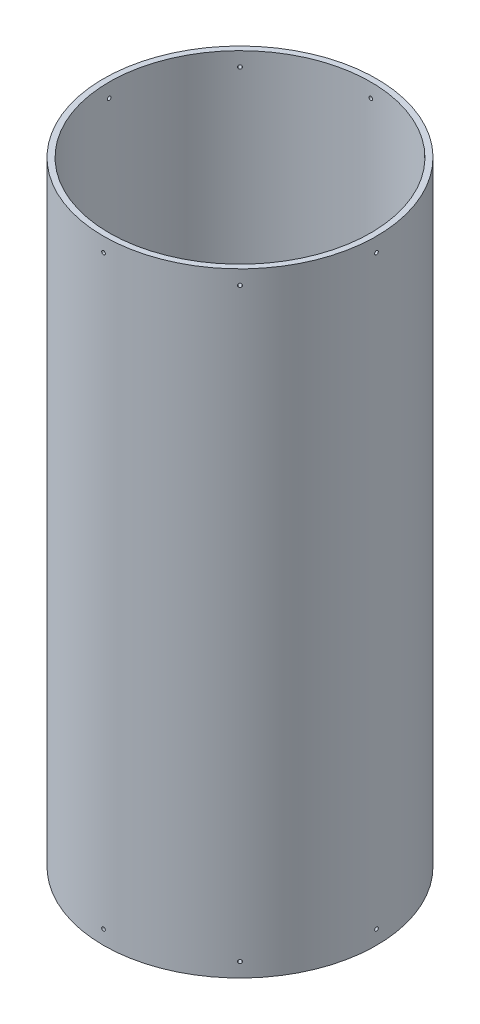
from build123d import *

# Parameters (mm, degrees)
SKETCH1_R                       = 152.4
SKETCH1_R_2                     = 146.05
BOSS_EXTRUDE1_DEPTH             = 685.8
F_10_32_TAPPED_HOLE1_AT_2_COUNT = 2
F_10_32_TAPPED_HOLE1_AT_2_PITCH = 654.05
CIRPATTERN1_COUNT               = 8
HOLE1_REACH                     = 767.801
HOLE1_BORE_R                    = 22.225


with BuildPart() as part:
    # Sketch1 → Boss-Extrude1 (new body)
    with BuildSketch(Plane(origin=(0, 0, 0), x_dir=(1, 0, 0), z_dir=(0, 1, 0))):
        with Locations(Location((0, 0, 0), (0, 0, 270))):
            Circle(SKETCH1_R)
        with Locations(Location((0, 0, 0), (0, 0, 270))):
            Circle(SKETCH1_R_2, mode=Mode.SUBTRACT)
    extrude(amount=BOSS_EXTRUDE1_DEPTH)

    # Sketch3 → #10-32 Tapped Hole1 (revolve, cut)
    with BuildSketch(Plane(origin=(0, 669.925, 152.4), x_dir=(0, -1, 0), z_dir=(1, 0, 0))):
        Polygon((0, 0), (0, 13.151317848), (2.0193, 11.938), (2.0193, 0), align=None)
    f_10_32_tapped_hole1 = revolve(axis=Axis((0, 669.925, 158.75), (0, 0, -1)), mode=Mode.SUBTRACT)

    # #10-32 Tapped Hole1 at 2: #10-32 Tapped Hole1 ×2
    with Locations(*[(0, -i * F_10_32_TAPPED_HOLE1_AT_2_PITCH, 0) for i in range(1, F_10_32_TAPPED_HOLE1_AT_2_COUNT)]):
        add(f_10_32_tapped_hole1, mode=Mode.SUBTRACT)

    # CirPattern1: #10-32 Tapped Hole1 ×8 about axis
    cirpattern1_axis = Axis((0, 0, 0), (0, 1, 0))
    for i in range(1, CIRPATTERN1_COUNT):
        add(f_10_32_tapped_hole1.rotate(cirpattern1_axis, i * 360 / CIRPATTERN1_COUNT), mode=Mode.SUBTRACT)

    # CirPattern1 copy 1 sketch → CirPattern1 copy 1 (revolve, cut)
    with BuildSketch(Plane(origin=(107.763073453, 15.875, 107.763073453), x_dir=(0, -1, 0), z_dir=(0.7071067811865476, 0, -0.7071067811865475))):
        Polygon((0, 0), (0, 13.151317848), (2.0193, 11.938), (2.0193, 0), align=None)
    revolve(axis=Axis((112.253201513, 15.875, 112.253201513), (-0.7071067811865475, 0, -0.7071067811865476)), mode=Mode.SUBTRACT)

    # CirPattern1 copy 2 sketch → CirPattern1 copy 2 (revolve, cut)
    with BuildSketch(Plane(origin=(152.4, 15.875, 0), x_dir=(0, -1, 0), z_dir=(0, 0, -1))):
        Polygon((0, 0), (0, 13.151317848), (2.0193, 11.938), (2.0193, 0), align=None)
    revolve(axis=Axis((158.75, 15.875, 0), (-1, 0, 0)), mode=Mode.SUBTRACT)

    # CirPattern1 copy 3 sketch → CirPattern1 copy 3 (revolve, cut)
    with BuildSketch(Plane(origin=(107.763073453, 15.875, -107.763073453), x_dir=(0, -1, 0), z_dir=(-0.7071067811865475, 0, -0.7071067811865476))):
        Polygon((0, 0), (0, 13.151317848), (2.0193, 11.938), (2.0193, 0), align=None)
    revolve(axis=Axis((112.253201513, 15.875, -112.253201513), (-0.7071067811865476, 0, 0.7071067811865475)), mode=Mode.SUBTRACT)

    # CirPattern1 copy 4 sketch → CirPattern1 copy 4 (revolve, cut)
    with BuildSketch(Plane(origin=(0, 15.875, -152.4), x_dir=(0, -1, 0), z_dir=(-1, 0, 0))):
        Polygon((0, 0), (0, 13.151317848), (2.0193, 11.938), (2.0193, 0), align=None)
    revolve(axis=Axis((0, 15.875, -158.75), (0, 0, 1)), mode=Mode.SUBTRACT)

    # CirPattern1 copy 5 sketch → CirPattern1 copy 5 (revolve, cut)
    with BuildSketch(Plane(origin=(-107.763073453, 15.875, -107.763073453), x_dir=(0, -1, 0), z_dir=(-0.7071067811865477, 0, 0.7071067811865475))):
        Polygon((0, 0), (0, 13.151317848), (2.0193, 11.938), (2.0193, 0), align=None)
    revolve(axis=Axis((-112.253201513, 15.875, -112.253201513), (0.7071067811865475, 0, 0.7071067811865477)), mode=Mode.SUBTRACT)

    # CirPattern1 copy 6 sketch → CirPattern1 copy 6 (revolve, cut)
    with BuildSketch(Plane(origin=(-152.4, 15.875, 0), x_dir=(0, -1, 0), z_dir=(0, 0, 1))):
        Polygon((0, 0), (0, 13.151317848), (2.0193, 11.938), (2.0193, 0), align=None)
    revolve(axis=Axis((-158.75, 15.875, 0), (1, 0, 0)), mode=Mode.SUBTRACT)

    # CirPattern1 copy 7 sketch → CirPattern1 copy 7 (revolve, cut)
    with BuildSketch(Plane(origin=(-107.763073453, 15.875, 107.763073453), x_dir=(0, -1, 0), z_dir=(0.7071067811865474, 0, 0.7071067811865477))):
        Polygon((0, 0), (0, 13.151317848), (2.0193, 11.938), (2.0193, 0), align=None)
    revolve(axis=Axis((-112.253201513, 15.875, 112.253201513), (0.7071067811865477, 0, -0.7071067811865474)), mode=Mode.SUBTRACT)

    # Hole1 bore → Hole1 (cut, up to next)
    with BuildSketch(Plane(origin=(-152.4, 0, 0), x_dir=(0, 0, -1), z_dir=(-1, 0, 0)), mode=Mode.PRIVATE) as hole1_sk1:
        with Locations((0, -104.775)):
            Circle(HOLE1_BORE_R)
    hole1_tool1 = extrude(hole1_sk1.sketch, amount=-HOLE1_REACH, mode=Mode.PRIVATE) & part.part
    add(hole1_tool1.solids().sort_by_distance((-152.4, 104.775, 0))[0], mode=Mode.SUBTRACT)


solid = part.part
